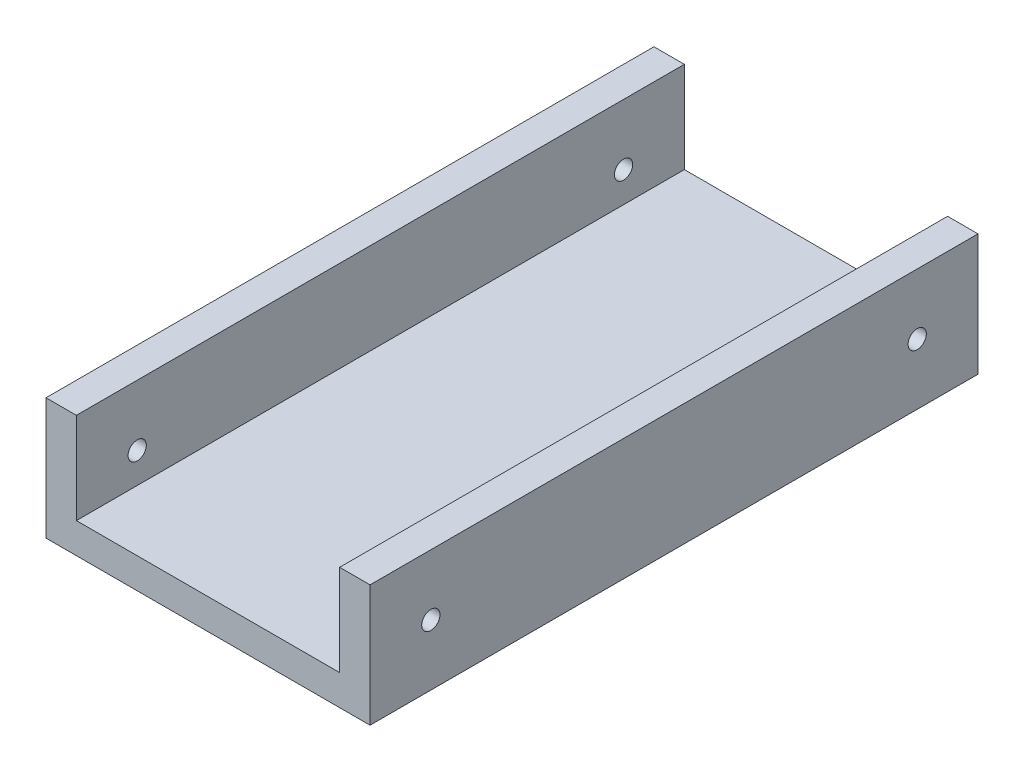
from build123d import *

# Parameters (mm, degrees)
ESQUISSE1_W             = 53.3
ESQUISSE1_H             = 100
BOSS_EXTRU_1_DEPTH      = 20
ESQUISSE2_W             = 43.3
ESQUISSE2_H             = 100
ENL_V_MAT_EXTRU_1_DEPTH = 15
ESQUISSE3_R             = 1.5
ENL_V_MAT_EXTRU_2_DEPTH = 54.3


with BuildPart() as part:
    # Esquisse1 → Boss.-Extru.1 (new body)
    with BuildSketch(Plane(origin=(0, 0, 0), x_dir=(1, 0, 0), z_dir=(0, 1, 0))):
        with Locations((26.65, -50)):
            Rectangle(ESQUISSE1_W, ESQUISSE1_H)
    extrude(amount=BOSS_EXTRU_1_DEPTH)

    # Esquisse2 → Enlèv. mat.-Extru.1 (cut)
    with BuildSketch(Plane(origin=(0, 20, 0), x_dir=(1, 0, 0), z_dir=(0, 1, 0))):
        with Locations((26.65, -50)):
            Rectangle(ESQUISSE2_W, ESQUISSE2_H)
    extrude(amount=-ENL_V_MAT_EXTRU_1_DEPTH, mode=Mode.SUBTRACT)

    # Esquisse3 → Enlèv. mat.-Extru.2 (cut, through all)
    with BuildSketch(Plane(origin=(53.3, 0, 0), x_dir=(0, 0, -1), z_dir=(1, 0, 0))):
        with Locations((-90, 10)):
            Circle(ESQUISSE3_R)
        with Locations((-10, 10)):
            Circle(ESQUISSE3_R)
    extrude(amount=-ENL_V_MAT_EXTRU_2_DEPTH, mode=Mode.SUBTRACT)


solid = part.part
